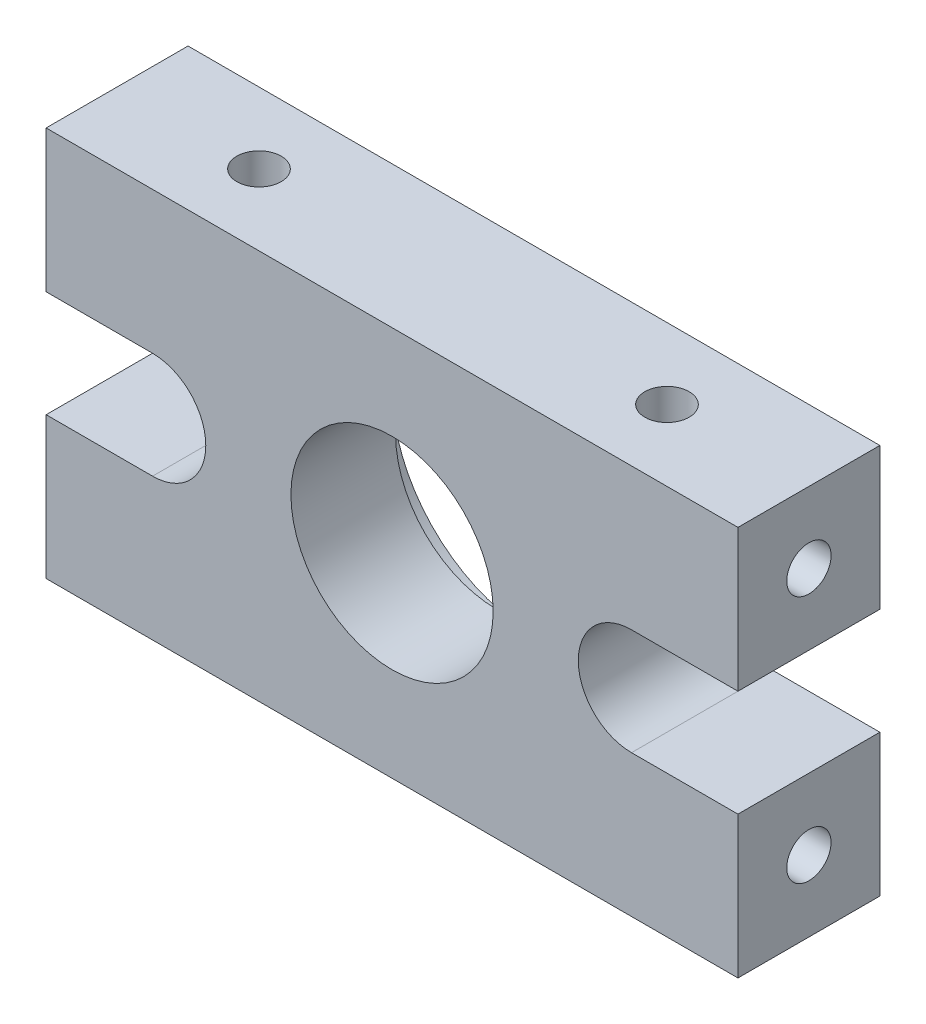
from build123d import *

# Parameters (mm, degrees)
SKETCH1_R                       = 5.7
BOSS_EXTRUDE1_DEPTH             = 8
TAP_DRILL_FOR_M3X0_5_TAP1_D     = 2.5
TAP_DRILL_FOR_M3X0_5_TAP1_DEPTH = 5
TAP_DRILL_FOR_M3X0_5_TAP1_TIP   = 0.751075774
TAP_DRILL_FOR_M3X0_5_TAP2_D     = 2.5
TAP_DRILL_FOR_M3X0_5_TAP2_DEPTH = 5
TAP_DRILL_FOR_M3X0_5_TAP2_TIP   = 0.751075774
TAP_DRILL_FOR_M3X0_5_TAP3_D     = 2.5
TAP_DRILL_FOR_M3X0_5_TAP3_DEPTH = 5
TAP_DRILL_FOR_M3X0_5_TAP3_TIP   = 0.751075774
SKETCH8_R                       = 8
CUT_EXTRUDE1_DEPTH              = 2.1


with BuildPart() as part:
    # Sketch1 → Boss-Extrude1 (new body)
    with BuildSketch(Plane.XY):
        with BuildLine():
            Line((0, 0), (39, 0))
            Line((39, 0), (39, 8))
            Line((39, 8), (33, 8))
            ThreePointArc((33, 8), (30, 11), (33, 14))
            Line((33, 14), (39, 14))
            Line((39, 14), (39, 22))
            Line((39, 22), (0, 22))
            Line((0, 22), (0, 14))
            Line((0, 14), (6, 14))
            ThreePointArc((6, 14), (9, 11), (6, 8))
            Line((6, 8), (0, 8))
            Line((0, 8), (0, 0))
        make_face()
        with Locations((19.5, 11)):
            Circle(SKETCH1_R, mode=Mode.SUBTRACT)
    extrude(amount=BOSS_EXTRUDE1_DEPTH)

    # Tap Drill for M3x0.5 Tap1
    with Locations(Plane(origin=(39, 0, 0), x_dir=(0, 0, -1), z_dir=(1, 0, 0))):
        with Locations((-4, 18), (-4, 4)):
            Hole(TAP_DRILL_FOR_M3X0_5_TAP1_D / 2, depth=TAP_DRILL_FOR_M3X0_5_TAP1_DEPTH)
            with Locations((0, 0, -(TAP_DRILL_FOR_M3X0_5_TAP1_DEPTH + TAP_DRILL_FOR_M3X0_5_TAP1_TIP / 2))):  # 118° drill point
                Cone(0, TAP_DRILL_FOR_M3X0_5_TAP1_D / 2, TAP_DRILL_FOR_M3X0_5_TAP1_TIP, mode=Mode.SUBTRACT)

    # Tap Drill for M3x0.5 Tap2
    with Locations(Plane.ZY):
        with Locations((4, 4), (4, 18)):
            Hole(TAP_DRILL_FOR_M3X0_5_TAP2_D / 2, depth=TAP_DRILL_FOR_M3X0_5_TAP2_DEPTH)
            with Locations((0, 0, -(TAP_DRILL_FOR_M3X0_5_TAP2_DEPTH + TAP_DRILL_FOR_M3X0_5_TAP2_TIP / 2))):  # 118° drill point
                Cone(0, TAP_DRILL_FOR_M3X0_5_TAP2_D / 2, TAP_DRILL_FOR_M3X0_5_TAP2_TIP, mode=Mode.SUBTRACT)

    # Tap Drill for M3x0.5 Tap3
    with Locations(Plane(origin=(0, 22, 0), x_dir=(1, 0, 0), z_dir=(0, 1, 0))):
        with Locations((31, -4), (8, -4)):
            Hole(TAP_DRILL_FOR_M3X0_5_TAP3_D / 2, depth=TAP_DRILL_FOR_M3X0_5_TAP3_DEPTH)
            with Locations((0, 0, -(TAP_DRILL_FOR_M3X0_5_TAP3_DEPTH + TAP_DRILL_FOR_M3X0_5_TAP3_TIP / 2))):  # 118° drill point
                Cone(0, TAP_DRILL_FOR_M3X0_5_TAP3_D / 2, TAP_DRILL_FOR_M3X0_5_TAP3_TIP, mode=Mode.SUBTRACT)

    # Sketch8 → Cut-Extrude1 (cut)
    with BuildSketch(Plane(origin=(0, 0, 0), x_dir=(-1, 0, 0), z_dir=(0, 0, -1))):
        with Locations((-19.5, 11)):
            Circle(SKETCH8_R)
    extrude(amount=-CUT_EXTRUDE1_DEPTH, mode=Mode.SUBTRACT)


solid = part.part
